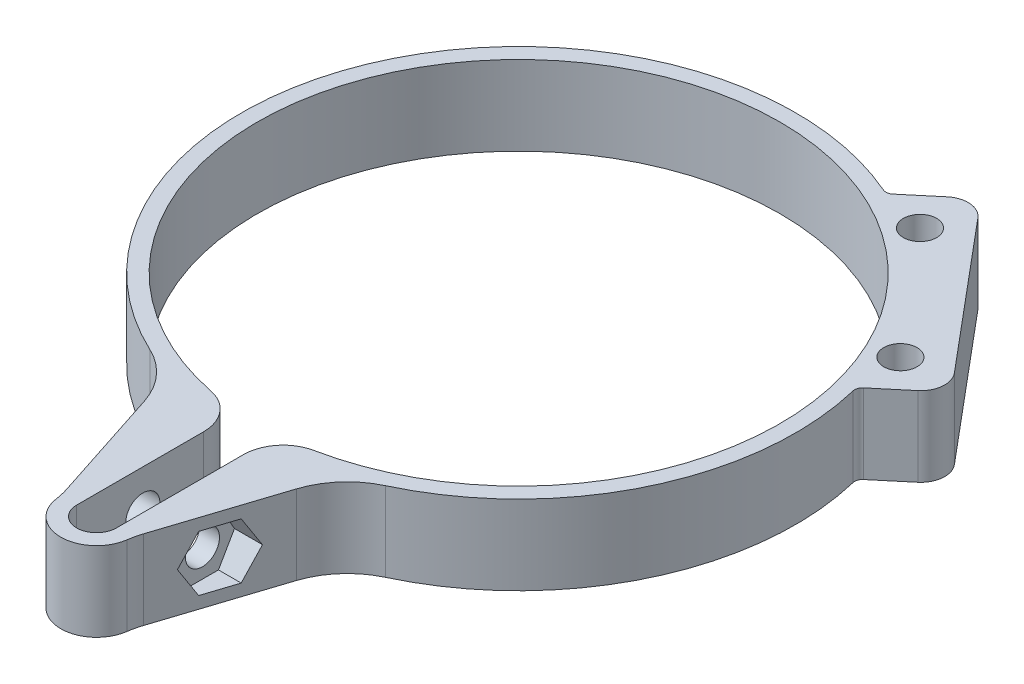
from build123d import *

# Parameters (mm, degrees)
SKETCH1_R               = 2.1
BOSS_EXTRUDE1_DEPTH     = 10
SKETCH3_R               = 2.15
CUT_EXTRUDE1_DEPTH      = 10
CUT_EXTRUDE1_DEPTH_BACK = 10
CUT_EXTRUDE2_START      = -6
SKETCH4_R               = 3.75
CUT_EXTRUDE2_DEPTH      = 10
CUT_EXTRUDE3_START      = -2.5
CUT_EXTRUDE3_DEPTH      = 10


with BuildPart() as part:
    # Sketch1 → Boss-Extrude1 (new body)
    with BuildSketch(Plane(origin=(0, 0, 0), x_dir=(1, 0, 0), z_dir=(0, 1, 0))):
        with BuildLine():
            Line((38.355229041, 16.51897107), (22.928326409, 34.904037705))
            ThreePointArc((22.928326409, 34.904037705), (20.891660307, 35.96425897), (18.70183025, 35.273808205))
            Line((18.70183025, 35.273808205), (14.981111589, 32.151754549))
            ThreePointArc((14.981111589, 32.151754549), (14.481497375, 31.928101372), (13.938983386, 32.000996346))
            ThreePointArc((13.938983386, 32.000996346), (-31.802778701, 14.385488935), (-14.829176591, -31.59833139))
            ThreePointArc((-14.829176591, -31.59833139), (-11.579923366, -34.034003552), (-9.567050503, -37.560827652))
            Line((-9.567050503, -37.560827652), (-4.848288245, -52.083684568))
            ThreePointArc((-4.848288245, -52.083684568), (-4.61517148, -52.924262884), (-4.456195885, -53.781958687))
            ThreePointArc((-4.456195885, -53.781958687), (-2.952237368, -56.551823245), (0, -57.655605566))
            ThreePointArc((0, -57.655605566), (2.952237368, -56.551823245), (4.456195885, -53.781958687))
            ThreePointArc((4.456195885, -53.781958687), (4.61517148, -52.924262884), (4.848288245, -52.083684568))
            Line((4.848288245, -52.083684568), (9.567050503, -37.560827652))
            ThreePointArc((9.567050503, -37.560827652), (11.579923366, -34.034003552), (14.829176591, -31.59833139))
            ThreePointArc((14.829176591, -31.59833139), (31.462355963, -15.115527853), (33.935308369, 8.170304209))
            ThreePointArc((33.935308369, 8.170304209), (33.957727399, 8.717234271), (34.264739879, 9.170421255))
            Line((34.264739879, 9.170421255), (37.985458541, 12.292474912))
            ThreePointArc((37.985458541, 12.292474912), (39.045679806, 14.329141013), (38.355229041, 16.51897107))
        make_face()
        with BuildLine():
            Line((-2.5, -53.155605566), (-2.5, -37.155605566))
            ThreePointArc((-2.5, -37.155605566), (-3.630466632, -33.989107261), (-6.510684606, -32.254457226))
            ThreePointArc((-6.510684606, -32.254457226), (0, 32.905), (6.510684606, -32.254457226))
            ThreePointArc((6.510684606, -32.254457226), (3.630466632, -33.989107261), (2.5, -37.155605566))
            Line((2.5, -37.155605566), (2.5, -53.155605566))
            ThreePointArc((2.5, -53.155605566), (0, -55.655605566), (-2.5, -53.155605566))
        make_face(mode=Mode.SUBTRACT)
        with Locations((20.383679412, 30.15801077)):
            Circle(SKETCH1_R, mode=Mode.SUBTRACT)
        with Locations((33.239431606, 14.837121908)):
            Circle(SKETCH1_R, mode=Mode.SUBTRACT)
    extrude(amount=BOSS_EXTRUDE1_DEPTH)

    # Sketch3 → Cut-Extrude1 (cut, two sides)
    with BuildSketch(Plane(origin=(0, 0, 0), x_dir=(0, 0, -1), z_dir=(1, 0, 0))) as cut_extrude1_sk:
        with Locations((-44.82225611, 5)):
            Circle(SKETCH3_R)
    extrude(amount=CUT_EXTRUDE1_DEPTH, mode=Mode.SUBTRACT)
    extrude(cut_extrude1_sk.sketch, amount=-CUT_EXTRUDE1_DEPTH_BACK, mode=Mode.SUBTRACT)

    # Sketch4 → Cut-Extrude2 (cut)
    with BuildSketch(Plane(origin=(0, 0, 0), x_dir=(0, 0, -1), z_dir=(1, 0, 0)).offset(CUT_EXTRUDE2_START)):
        with Locations((-44.82225611, 5)):
            Circle(SKETCH4_R)
    extrude(amount=-CUT_EXTRUDE2_DEPTH, mode=Mode.SUBTRACT)

    # Sketch5 → Cut-Extrude3 (cut)
    with BuildSketch(Plane.ZY.offset(-2.5).offset(CUT_EXTRUDE3_START)):
        Polygon((46.842982052, 8.5), (42.801530168, 8.5), (40.780804226, 5), (42.801530168, 1.5), (46.842982052, 1.5), (48.863707994, 5), align=None)
    extrude(amount=-CUT_EXTRUDE3_DEPTH, mode=Mode.SUBTRACT)


solid = part.part
